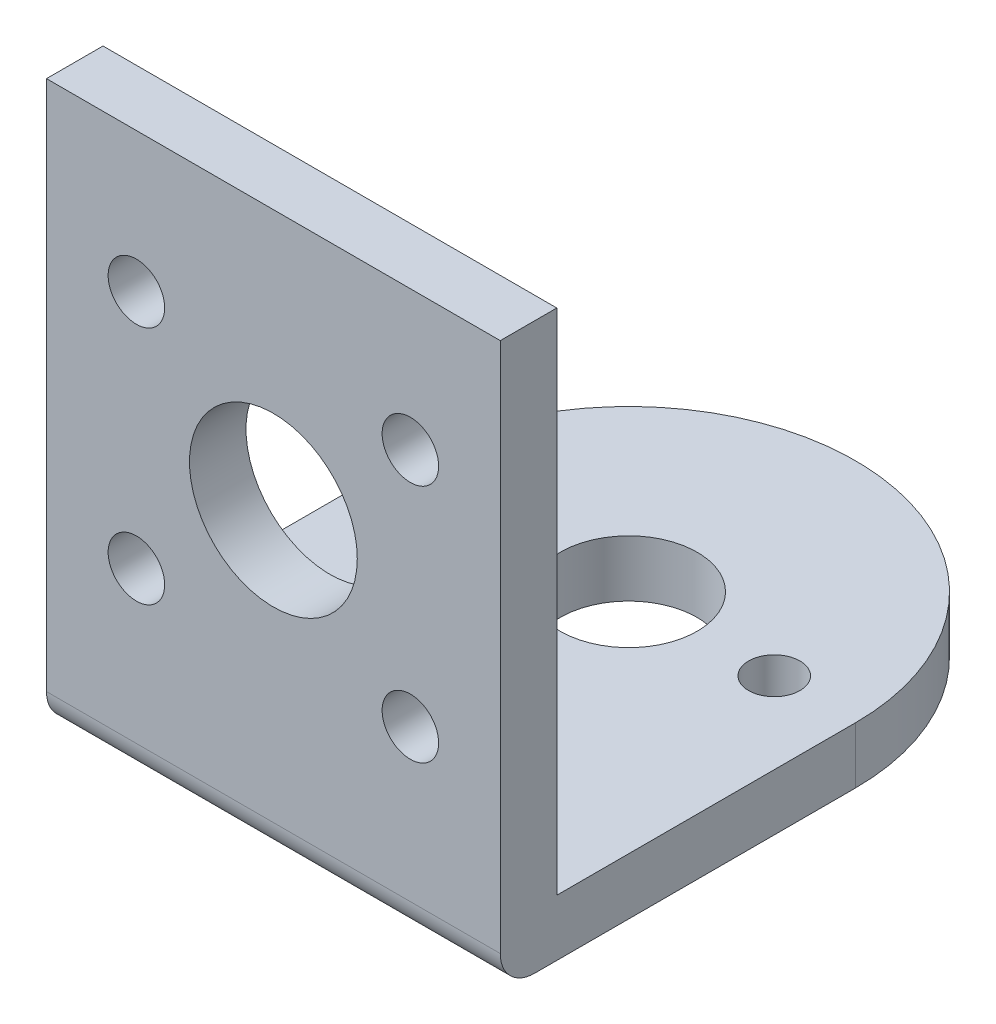
from build123d import *

# Parameters (mm, degrees)
BASE_FACE_R         = 4
BASE_FACE_R_2       = 1.5
BASE_DEPTH          = 3.3
SKETCH3_W           = 26.5
SKETCH3_H           = 33
SKETCH3_R           = 4.9
SKETCH3_R_2         = 1.65
BOSS_EXTRUDE2_DEPTH = 3.3
FILLET1_R           = 2


with BuildPart() as part:
    # Base Face → Base (new body)
    with BuildSketch(Plane(origin=(0, 0, 0), x_dir=(1, 0, 0), z_dir=(0, 1, 0))):
        with BuildLine():
            Line((-13.25, 0), (-13.25, -20.75))
            Line((-13.25, -20.75), (13.25, -20.75))
            Line((13.25, -20.75), (13.25, 0))
            ThreePointArc((13.25, 0), (0, 13.25), (-13.25, 0))
        make_face()
        Circle(BASE_FACE_R, mode=Mode.SUBTRACT)
        with Locations((-8.5, 0)):
            Circle(BASE_FACE_R_2, mode=Mode.SUBTRACT)
        with Locations((8.5, 0)):
            Circle(BASE_FACE_R_2, mode=Mode.SUBTRACT)
    extrude(amount=BASE_DEPTH)

    # Sketch3 → Boss-Extrude2 (add)
    with BuildSketch(Plane.XY.offset(20.75)):
        with Locations((0, 16.5)):
            Rectangle(SKETCH3_W, SKETCH3_H)
        with Locations((0, 17.8)):
            Circle(SKETCH3_R, mode=Mode.SUBTRACT)
        with Locations((8, 10.85)):
            Circle(SKETCH3_R_2, mode=Mode.SUBTRACT)
        with Locations((8, 24.85)):
            Circle(SKETCH3_R_2, mode=Mode.SUBTRACT)
        with Locations((-8, 10.85)):
            Circle(SKETCH3_R_2, mode=Mode.SUBTRACT)
        with Locations((-8, 24.85)):
            Circle(SKETCH3_R_2, mode=Mode.SUBTRACT)
    extrude(amount=-BOSS_EXTRUDE2_DEPTH)

    # Fillet1
    fillet1_edges = [part.edges().sort_by_distance(p)[0] for p in [
        (0, 0, 20.75),
    ]]
    fillet(fillet1_edges, radius=FILLET1_R)


solid = part.part
